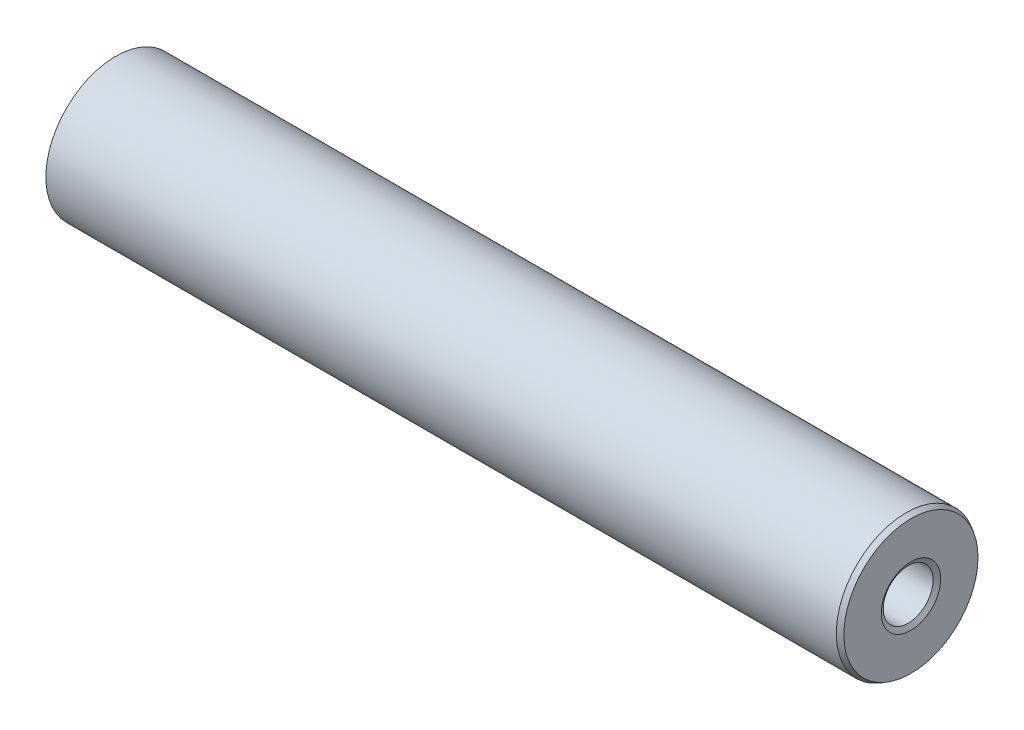
from build123d import *
from OCP.BRepFilletAPI import BRepFilletAPI_MakeChamfer

# Parameters (mm, degrees)
SKETCH1_R           = 11.1125
SKETCH1_R_2         = 3.96875
BOSS_EXTRUDE1_DEPTH = 127
CHAMFER1_SIZE       = 0.762
CHAMFER1_SIZE2      = 0.439940905


with BuildPart() as part:
    # Sketch1 → Boss-Extrude1 (new body)
    with BuildSketch(Plane(origin=(0, 0, 0), x_dir=(0, 0, -1), z_dir=(1, 0, 0))):
        Circle(SKETCH1_R)
        Circle(SKETCH1_R_2, mode=Mode.SUBTRACT)
    extrude(amount=BOSS_EXTRUDE1_DEPTH)

    # Chamfer1: one chamfer whose edges measure the first distance from different faces: ONE call of the kernel's chamfer builder (chamfer() names one face for all edges)
    chamfer1_edges_1 = [part.edges().sort_by_distance(p)[0] for p in [
        (0, 0, 11.1125),
    ]]
    chamfer1_side_1 = [part.faces().sort_by_distance(p)[0] for p in [
        (0, 0, 10.798191036),
    ]]
    chamfer1_edges_2 = [part.edges().sort_by_distance(p)[0] for p in [
        (127, 0, 11.1125),
    ]]
    chamfer1_side_2 = [part.faces().sort_by_distance(p)[0] for p in [
        (63.5, 0, 11.1125),
    ]]
    chamfer1_edges_3 = [part.edges().sort_by_distance(p)[0] for p in [
        (0, 0, 3.96875),
    ]]
    chamfer1_side_3 = [part.faces().sort_by_distance(p)[0] for p in [
        (63.5, 0, 3.96875),
    ]]
    chamfer1_edges_4 = [part.edges().sort_by_distance(p)[0] for p in [
        (127, 0, 3.96875),
    ]]
    chamfer1_side_4 = [part.faces().sort_by_distance(p)[0] for p in [
        (127, 0, 10.798191036),
    ]]
    chamfer1 = BRepFilletAPI_MakeChamfer(part.part.solid().wrapped)
    for e in chamfer1_edges_1:
        chamfer1.Add(CHAMFER1_SIZE, CHAMFER1_SIZE2, e.wrapped, chamfer1_side_1[0].wrapped)  # the first distance lies on this face
    for e in chamfer1_edges_2:
        chamfer1.Add(CHAMFER1_SIZE, CHAMFER1_SIZE2, e.wrapped, chamfer1_side_2[0].wrapped)  # the first distance lies on this face
    for e in chamfer1_edges_3:
        chamfer1.Add(CHAMFER1_SIZE, CHAMFER1_SIZE2, e.wrapped, chamfer1_side_3[0].wrapped)  # the first distance lies on this face
    for e in chamfer1_edges_4:
        chamfer1.Add(CHAMFER1_SIZE, CHAMFER1_SIZE2, e.wrapped, chamfer1_side_4[0].wrapped)  # the first distance lies on this face
    add(Compound.cast(chamfer1.Shape()), mode=Mode.REPLACE)


solid = part.part
